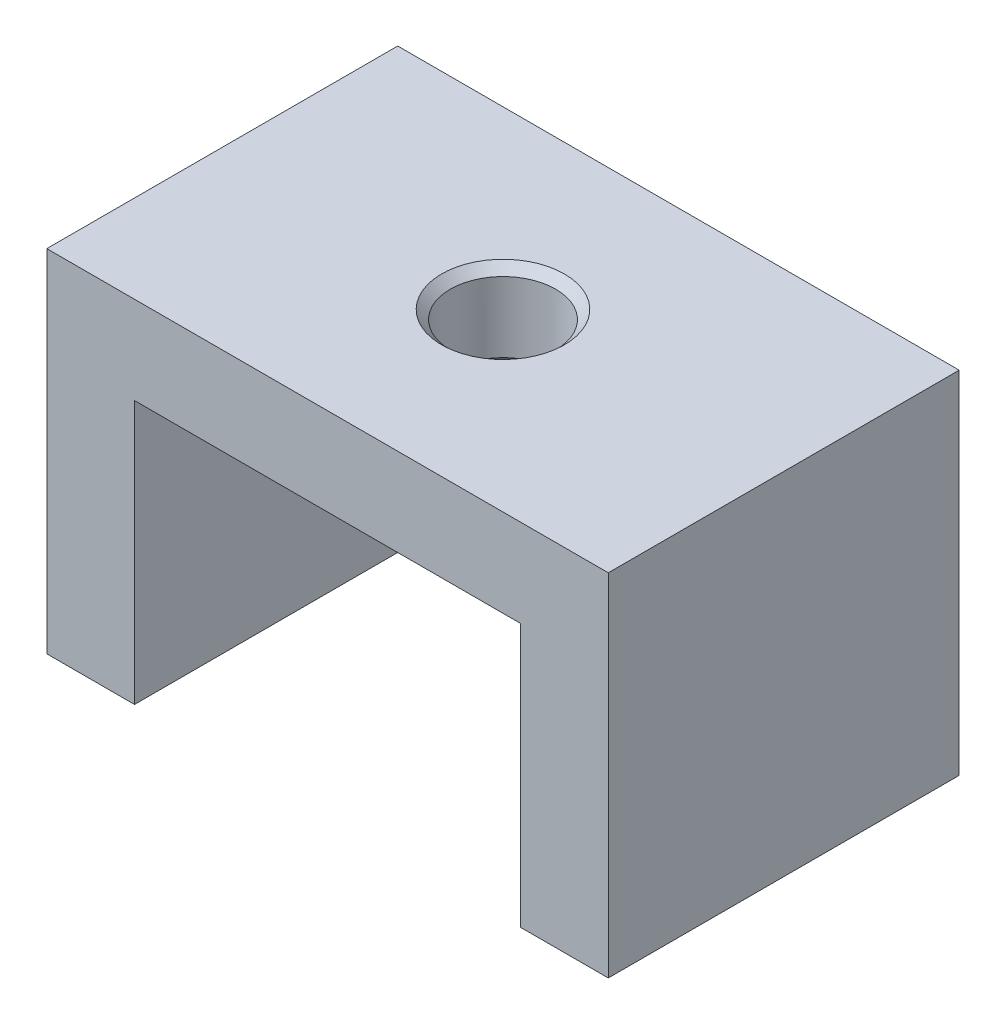
from build123d import *

# Parameters (mm, degrees)
BOSS_EXTRU_1_DEPTH      = 10
ESQUISSE2_R             = 3
ENL_V_MAT_EXTRU_1_DEPTH = 21
CHANFREIN1_SIZE         = 0.5
TROU_TARAUD_M41_D       = 3.3
TROU_TARAUD_M41_DEPTH   = 10.1
TROU_TARAUD_M41_TIP     = 0.991420021


with BuildPart() as part:
    # Esquisse1 → Boss.-Extru.1 (new body, symmetric)
    with BuildSketch(Plane.XY):
        Polygon((-16, 20), (16, 20), (16, 0), (11, 0), (11, 15), (-11, 15), (-11, 0), (-16, 0), align=None)
    extrude(amount=BOSS_EXTRU_1_DEPTH, both=True)

    # Esquisse2 → Enlèv. mat.-Extru.1 (cut, through all)
    with BuildSketch(Plane(origin=(0, 20, 0), x_dir=(1, 0, 0), z_dir=(0, 1, 0))):
        Circle(ESQUISSE2_R)
    extrude(amount=-ENL_V_MAT_EXTRU_1_DEPTH, mode=Mode.SUBTRACT)

    # Chanfrein1
    chanfrein1_edges = [part.edges().sort_by_distance(p)[0] for p in [
        (-3, 15, 0),
        (-3, 20, 0),
    ]]
    chamfer(chanfrein1_edges, length=CHANFREIN1_SIZE)

    # Trou taraudé M41
    with Locations(Plane.XZ):
        with Locations((13.5, 5), (-13.5, -5), (-13.5, 5), (13.5, -5)):
            Hole(TROU_TARAUD_M41_D / 2, depth=TROU_TARAUD_M41_DEPTH)
            with Locations((0, 0, -(TROU_TARAUD_M41_DEPTH + TROU_TARAUD_M41_TIP / 2))):  # 118° drill point
                Cone(0, TROU_TARAUD_M41_D / 2, TROU_TARAUD_M41_TIP, mode=Mode.SUBTRACT)


solid = part.part
